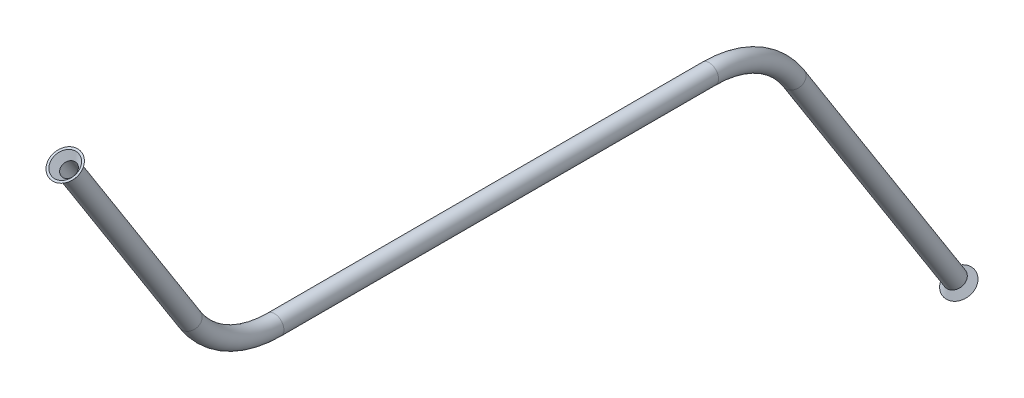
from build123d import *

# Parameters (mm, degrees)
SKETCH1_R           = 2.38125
SKETCH1_R_2         = 1.82245
SKETCH4_R           = 2.38125
SKETCH4_R_2         = 1.82245
SKETCH5_R           = 2.38125
BOSS_EXTRUDE1_DEPTH = 1.778
BOSS_EXTRUDE1_DRAFT = -37
SKETCH6_R           = 1.82245
CUT_EXTRUDE1_DEPTH  = 6.146397849
CUT_EXTRUDE1_DRAFT  = 37
SKETCH7_R           = 2.38125
BOSS_EXTRUDE2_DEPTH = 1.778
BOSS_EXTRUDE2_DRAFT = -37
SKETCH8_R           = 1.82245
CUT_EXTRUDE2_DEPTH  = 6.146397849
CUT_EXTRUDE2_DRAFT  = 37


with BuildPart() as part:
    # Sweep2: sweep along a path in Sketch2
    with BuildLine(Plane(origin=(0, 0, 0), x_dir=(0, 0, -1), z_dir=(1, 0, 0))) as sweep2_path:
        Line((0, 0), (110.130707173, 0))
        ThreePointArc((110.130707173, 0), (122.362068558, -3.138962318), (131.570297464, -11.780015853))
        Line((131.570297464, -11.780015853), (172.430249905, -76.098786725))
    # Sketch1 → Sweep2 (sweep)
    with BuildSketch(Plane.XY):
        Circle(SKETCH1_R)
        Circle(SKETCH1_R_2, mode=Mode.SUBTRACT)
    sweep(path=sweep2_path.line)

    # Sweep3: sweep along a path in Sketch3
    with BuildLine(Plane(origin=(0, 0, 0), x_dir=(0, 0, -1), z_dir=(1, 0, 0))) as sweep3_path:
        Line((-52.084554622, 60.019094007), (-21.439590291, 11.780015853))
        ThreePointArc((-21.439590291, 11.780015853), (-12.231361385, 3.138962318), (0, 0))
    # Sketch4 → Sweep3 (sweep)
    with BuildSketch(Plane.XY):
        Circle(SKETCH4_R)
        Circle(SKETCH4_R_2, mode=Mode.SUBTRACT)
    sweep(path=sweep3_path.line)


with BuildPart() as boss_extrude1_tool:
    # Sketch5 → Boss-Extrude1 (with draft: the straight prism first)
    with BuildSketch(Plane(origin=(0, 66.335772321, 42.141298184), x_dir=(1, 0, 0), z_dir=(0, 0.844078358, 0.536219848))):
        with Locations(Location((0, -11.780015853, 0), (0, 0, 270))):  # turned: the seam where the file's is
            Circle(SKETCH5_R)
    extrude(amount=BOSS_EXTRUDE1_DEPTH)
    # Boss-Extrude1: the draft: its side faces are tilted about the plane it starts from
    boss_extrude1_sides = [boss_extrude1_tool.faces().sort_by_distance(p)[0] for p in [
        (0, 62.046353181, 50.551292477),
    ]]
    draft(boss_extrude1_sides, Plane(origin=(0, 66.335772321, 42.141298184), x_dir=(1, 0, 0), z_dir=(0, 0.844078358, 0.536219848)), BOSS_EXTRUDE1_DRAFT)


with BuildPart() as part_1:
    add(part.part)

    # Boss-Extrude1: add boss_extrude1_tool
    add(boss_extrude1_tool.part)


with BuildPart() as cut_extrude1_tool:
    # Sketch6 → Cut-Extrude1 (with draft: the straight prism first)
    with BuildSketch(Plane(origin=(0, 66.335772321, 42.141298184), x_dir=(1, 0, 0), z_dir=(0, -0.844078358, -0.536219848))):
        with Locations(Location((0, 11.780015853, 0), (0, 0, 90))):  # turned: the seam where the file's is
            Circle(SKETCH6_R)
    extrude(amount=-CUT_EXTRUDE1_DEPTH)
    # Cut-Extrude1: the draft: its side faces are tilted about the plane it starts from
    cut_extrude1_sides = [cut_extrude1_tool.faces().sort_by_distance(p)[0] for p in [
        (0, 63.590348571, 52.194174279),
    ]]
    draft(cut_extrude1_sides, Plane(origin=(0, 66.335772321, 42.141298184), x_dir=(1, 0, 0), z_dir=(0, -0.844078358, -0.536219848)), CUT_EXTRUDE1_DRAFT)


with BuildPart() as part_2:
    add(part_1.part)

    # Cut-Extrude1: cut by cut_extrude1_tool
    add(cut_extrude1_tool.part, mode=Mode.SUBTRACT)


with BuildPart() as boss_extrude2_tool:
    # Sketch7 → Boss-Extrude2 (with draft: the straight prism first)
    with BuildSketch(Plane(origin=(0, -132.261897211, -84.022358583), x_dir=(1, 0, 0), z_dir=(0, -0.844078358, -0.536219848))):
        with Locations(Location((0, -104.738962318, 0), (0, 0, 270))):  # turned: the seam where the file's is
            Circle(SKETCH7_R)
    extrude(amount=BOSS_EXTRUDE2_DEPTH)
    # Boss-Extrude2: the draft: its side faces are tilted about the plane it starts from
    boss_extrude2_sides = [boss_extrude2_tool.faces().sort_by_distance(p)[0] for p in [
        (0, -78.126045899, -170.89698776),
    ]]
    draft(boss_extrude2_sides, Plane(origin=(0, -132.261897211, -84.022358583), x_dir=(1, 0, 0), z_dir=(0, -0.844078358, -0.536219848)), BOSS_EXTRUDE2_DRAFT)


with BuildPart() as part_3:
    add(part_2.part)

    # Boss-Extrude2: add boss_extrude2_tool
    add(boss_extrude2_tool.part)


with BuildPart() as cut_extrude2_tool:
    # Sketch8 → Cut-Extrude2 (with draft: the straight prism first)
    with BuildSketch(Plane(origin=(0, -132.261897211, -84.022358583), x_dir=(1, 0, 0), z_dir=(0, 0.844078358, 0.536219848))):
        with Locations(Location((0, 104.738962318, 0), (0, 0, 90))):  # turned: the seam where the file's is
            Circle(SKETCH8_R)
    extrude(amount=-CUT_EXTRUDE2_DEPTH)
    # Cut-Extrude2: the draft: its side faces are tilted about the plane it starts from
    cut_extrude2_sides = [cut_extrude2_tool.faces().sort_by_distance(p)[0] for p in [
        (0, -79.670041289, -172.539869562),
    ]]
    draft(cut_extrude2_sides, Plane(origin=(0, -132.261897211, -84.022358583), x_dir=(1, 0, 0), z_dir=(0, 0.844078358, 0.536219848)), CUT_EXTRUDE2_DRAFT)


with BuildPart() as part_4:
    add(part_3.part)

    # Cut-Extrude2: cut by cut_extrude2_tool
    add(cut_extrude2_tool.part, mode=Mode.SUBTRACT)


solid = part_4.part
